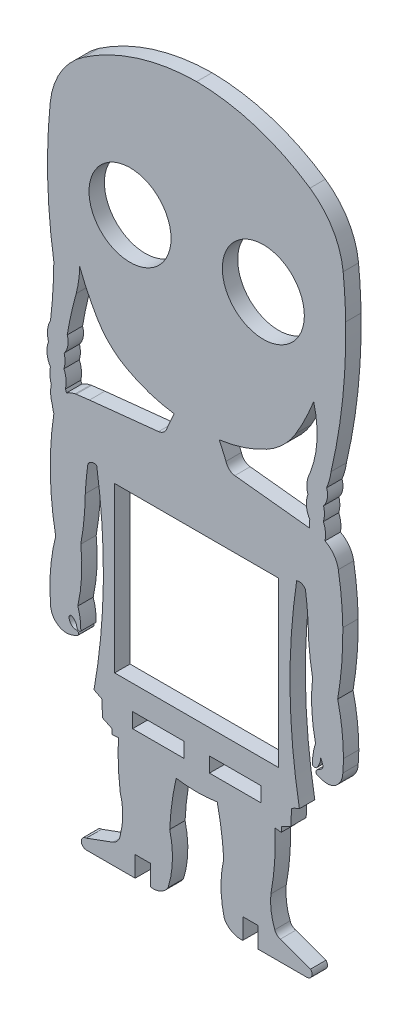
from build123d import *

# Parameters (mm, degrees)
MODEL_R                 = 8
MODEL_W                 = 10
MODEL_H                 = 2.9
MODEL_W_2               = 32
MODEL_H_2               = 32
SALIENTE_EXTRUIR1_DEPTH = 3


with BuildPart() as part:
    # Model → Saliente-Extruir1 (new body)
    with BuildSketch(Plane.XY):
        with BuildLine():
            Line((38.13338625, -11.98902119), (39.653006529, -12.774243223))
            Line((39.653006529, -12.774243223), (39.802898244, -15.912303294))
            Line((39.802898244, -15.912303294), (41.659424282, -16.81226138))
            Line((41.659424282, -16.81226138), (41.659570627, -17.81226137))
            Line((41.659570627, -17.81226137), (42.885100365, -17.686085819))
            ThreePointArc((42.885100365, -17.686085819), (42.872802779, -22.221519016), (43.240098472, -26.742072012))
            ThreePointArc((43.240098472, -26.742072012), (43.741813509, -30.284540527), (43.277058391, -33.832047235))
            ThreePointArc((43.277058391, -33.832047235), (42.843713702, -35.071902085), (41.821747011, -35.896894057))
            Line((41.821747011, -35.896894057), (36.619576914, -37.805682401))
            ThreePointArc((36.619576914, -37.805682401), (35.648987396, -38.830697612), (36.66279026, -39.812992857))
            Line((36.66279026, -39.812992857), (46.161532701, -39.811602768))
            Line((46.161532701, -39.811602768), (46.160947323, -35.811602811))
            Line((46.160947323, -35.811602811), (49.156750321, -35.811164391))
            Line((49.156750321, -35.811164391), (49.161532531, -39.810221609))
            ThreePointArc((49.161532531, -39.810221609), (51.099825083, -39.514249492), (52.57645016, -38.224227828))
            ThreePointArc((52.57645016, -38.224227828), (53.427829994, -33.234025723), (52.896261461, -28.199703568))
            ThreePointArc((52.896261461, -28.199703568), (53.321482121, -23.531856748), (54.153881511, -18.919187477))
            ThreePointArc((54.153881511, -18.919187477), (58.157636, -19.235830008), (62.161344106, -18.918601553))
            ThreePointArc((62.161344106, -18.918601553), (62.974942691, -23.410097559), (63.434714055, -27.951472827))
            ThreePointArc((63.434714055, -27.951472827), (62.903519075, -32.937753167), (63.54579815, -37.910945033))
            ThreePointArc((63.54579815, -37.910945033), (65.056116274, -39.421668423), (67.156750321, -39.809846983))
            Line((67.156750321, -39.809846983), (67.156750321, -35.809846983))
            Line((67.156750321, -35.809846983), (70.156750321, -35.809846983))
            Line((70.156750321, -35.809846983), (70.156750321, -39.809846983))
            Line((70.156750321, -39.809846983), (79.693755496, -39.809445684))
            ThreePointArc((79.693755496, -39.809445684), (80.593657018, -39.149406826), (80.377002549, -38.054630646))
            Line((80.377002549, -38.054630646), (74.477680062, -35.933884761))
            ThreePointArc((74.477680062, -35.933884761), (73.797838269, -35.555941667), (73.390760584, -34.8931343))
            ThreePointArc((73.390760584, -34.8931343), (72.679975093, -32.105941725), (72.627396562, -29.23002553))
            ThreePointArc((72.627396562, -29.23002553), (73.363432338, -23.480206676), (73.429944674, -17.683850784))
            Line((73.429944674, -17.683850784), (74.655492864, -17.809846983))
            Line((74.655492864, -17.809846983), (74.655492864, -16.809846983))
            Line((74.655492864, -16.809846983), (76.511887179, -15.909617214))
            Line((76.511887179, -15.909617214), (76.661319654, -12.771535241))
            ThreePointArc((76.661319654, -12.771535241), (77.407588898, -12.361254496), (78.198982306, -12.046699973))
            ThreePointArc((78.198982306, -12.046699973), (76.369057771, 7.049663622), (77.658007778, 26.190153017))
            ThreePointArc((77.658007778, 26.190153017), (78.625759658, 26.202004714), (79.370870097, 25.584352225))
            ThreePointArc((79.370870097, 25.584352225), (79.683559437, 22.93101885), (79.884170291, 20.26686647))
            ThreePointArc((79.884170291, 20.26686647), (80.128803281, 15.76516974), (80.75659962, 11.300755949))
            ThreePointArc((80.75659962, 11.300755949), (80.608595679, 5.911597181), (81.336651671, 0.569793003))
            ThreePointArc((81.336651671, 0.569793003), (80.874239414, -1.377695927), (80.75123227, -3.375546641))
            ThreePointArc((80.75123227, -3.375546641), (81.132788068, -3.557162673), (81.54344173, -3.457499344))
            ThreePointArc((81.54344173, -3.457499344), (82.123620398, -2.472655714), (82.365920426, -1.355599334))
            Line((82.365920426, -1.355599334), (82.731532261, -2.337573054))
            ThreePointArc((82.731532261, -2.337573054), (82.716273485, -2.891757606), (82.348186231, -3.306323791))
            ThreePointArc((82.348186231, -3.306323791), (81.9194858, -3.566874198), (81.519346366, -3.869461388))
            ThreePointArc((81.519346366, -3.869461388), (81.394346017, -4.250479501), (81.594913038, -4.597715386))
            ThreePointArc((81.594913038, -4.597715386), (82.546157979, -4.951267012), (83.546305166, -5.123230082))
            ThreePointArc((83.546305166, -5.123230082), (84.803821734, -4.845241985), (85.812572918, -4.044588284))
            ThreePointArc((85.812572918, -4.044588284), (86.435586593, -3.002992591), (86.658007778, -1.809846983))
            ThreePointArc((86.658007778, -1.809846983), (86.739204411, -0.560861795), (86.777674837, 0.690168549))
            ThreePointArc((86.777674837, 0.690168549), (86.496792688, 5.47303796), (85.658007778, 10.190153017))
            ThreePointArc((85.658007778, 10.190153017), (86.445024112, 16.448601458), (86.659989285, 22.752676456))
            ThreePointArc((86.659989285, 22.752676456), (86.395853577, 27.453838391), (85.786017751, 32.122755982))
            ThreePointArc((85.786017751, 32.122755982), (84.900900015, 34.200326378), (83.191960731, 35.67655762))
            ThreePointArc((83.191960731, 35.67655762), (83.267506137, 37.256812295), (82.874566252, 38.789297269))
            ThreePointArc((82.874566252, 38.789297269), (83.076029916, 40.128033113), (82.908147107, 41.471393314))
            ThreePointArc((82.908147107, 41.471393314), (83.636168036, 43.069749641), (83.50522588, 44.821209481))
            ThreePointArc((83.50522588, 44.821209481), (84.042102073, 46.362379689), (84.364424293, 47.962239071))
            ThreePointArc((84.364424293, 47.962239071), (86.618595537, 61.237849866), (87.224806715, 74.68982511))
            ThreePointArc((87.224806715, 74.68982511), (87.056800285, 78.802763925), (86.728271279, 82.906001738))
            ThreePointArc((86.728271279, 82.906001738), (84.700461487, 89.074609987), (80.255619321, 93.808225772))
            ThreePointArc((80.255619321, 93.808225772), (69.72067189, 98.917356509), (58.156750321, 100.751491783))
            ThreePointArc((58.156750321, 100.751491783), (46.592828752, 98.917356509), (36.057881322, 93.808225772))
            ThreePointArc((36.057881322, 93.808225772), (31.613039156, 89.074609987), (29.585229363, 82.906001738))
            ThreePointArc((29.585229363, 82.906001738), (29.102545512, 69.627136778), (30.294955036, 56.393112527))
            ThreePointArc((30.294955036, 56.393112527), (30.113174416, 51.282986839), (29.655492864, 46.190153017))
            ThreePointArc((29.655492864, 46.190153017), (29.082963004, 44.310971202), (29.250253195, 42.353644268))
            ThreePointArc((29.250253195, 42.353644268), (28.963838604, 40.285926549), (29.618806019, 38.303880241))
            ThreePointArc((29.618806019, 38.303880241), (29.530635351, 36.823427951), (29.802364542, 35.365458028))
            ThreePointArc((29.802364542, 35.365458028), (29.675044266, 33.719440486), (30.000786224, 32.100960836))
            ThreePointArc((30.000786224, 32.100960836), (30.110421583, 31.410758304), (30.299083762, 30.73784967))
            ThreePointArc((30.299083762, 30.73784967), (29.605599069, 20.448881499), (30.655492864, 10.190153017))
            ThreePointArc((30.655492864, 10.190153017), (29.658917683, 4.231534282), (29.655492864, -1.809846983))
            ThreePointArc((29.655492864, -1.809846983), (29.877914049, -3.002992591), (30.500927724, -4.044588284))
            ThreePointArc((30.500927724, -4.044588284), (31.814902322, -4.920630356), (33.391717798, -5.007991174))
            ThreePointArc((33.391717798, -5.007991174), (34.137122565, -4.790515502), (34.843036496, -4.467081651))
            ThreePointArc((34.843036496, -4.467081651), (35.127127166, -3.999561224), (34.739159104, -3.613862324))
            ThreePointArc((34.739159104, -3.613862324), (33.67716173, -3.184791782), (33.283131978, -2.10930096))
            ThreePointArc((33.283131978, -2.10930096), (33.494826851, -1.718657356), (33.938344185, -1.745294179))
            ThreePointArc((33.938344185, -1.745294179), (34.493195611, -2.316132502), (34.787693342, -3.055718592))
            ThreePointArc((34.787693342, -3.055718592), (34.985784548, -3.414741828), (35.387363334, -3.497641092))
            ThreePointArc((35.387363334, -3.497641092), (35.476115329, -3.445875915), (35.555217619, -3.380306275))
            ThreePointArc((35.555217619, -3.380306275), (35.439451794, -1.379324135), (34.975517408, 0.570572308))
            ThreePointArc((34.975517408, 0.570572308), (35.70649142, 5.91220389), (35.555930222, 11.301515747))
            ThreePointArc((35.555930222, 11.301515747), (36.184195727, 15.765528896), (36.429330352, 20.26686647))
            ThreePointArc((36.429330352, 20.26686647), (36.629941206, 22.93101885), (36.942630546, 25.584352225))
            ThreePointArc((36.942630546, 25.584352225), (37.687740984, 26.202004714), (38.655492864, 26.190153017))
            ThreePointArc((38.655492864, 26.190153017), (39.951524478, 7.079272516), (38.13338625, -11.98902119))
        make_face()
        with Locations((45.156750321, 71.712196279)):
            Circle(MODEL_R, mode=Mode.SUBTRACT)
        with Locations((71.156750321, 71.712196279)):
            Circle(MODEL_R, mode=Mode.SUBTRACT)
        with BuildLine():
            Line((62.563797699, 42.448688608), (63.883863041, 39.480536552))
            ThreePointArc((63.883863041, 39.480536552), (64.489395861, 38.422507509), (65.596662509, 37.912550624))
            Line((65.596662509, 37.912550624), (80.129802187, 36.337902427))
            ThreePointArc((80.129802187, 36.337902427), (80.131262399, 37.066798655), (80.219659568, 37.7903163))
            ThreePointArc((80.219659568, 37.7903163), (79.564692153, 39.772362608), (79.851106744, 41.840080327))
            ThreePointArc((79.851106744, 41.840080327), (79.683816553, 43.797407261), (80.256346413, 45.676589076))
            ThreePointArc((80.256346413, 45.676589076), (81.623379165, 51.836282911), (80.978461998, 58.112801734))
            ThreePointArc((80.978461998, 58.112801734), (79.388294211, 54.465766157), (77.499872133, 50.963857515))
            ThreePointArc((77.499872133, 50.963857515), (75.026874588, 47.839044876), (71.818346679, 45.475674498))
            ThreePointArc((71.818346679, 45.475674498), (67.331870743, 43.531711387), (62.563797699, 42.448688608))
        make_face(mode=Mode.SUBTRACT)
        with BuildLine():
            Line((34.438521627, 36.148814617), (34.657873731, 36.19094302))
            Line((34.657873731, 36.19094302), (37.252216007, 36.508696647))
            Line((37.252216007, 36.508696647), (50.716761984, 37.912867984))
            ThreePointArc((50.716761984, 37.912867984), (51.824045775, 38.422787644), (52.429614164, 39.480796329))
            Line((52.429614164, 39.480796329), (53.749684561, 42.448691023))
            ThreePointArc((53.749684561, 42.448691023), (48.981621088, 43.531714269), (44.495153964, 45.475674498))
            ThreePointArc((44.495153964, 45.475674498), (41.286626055, 47.839044876), (38.813628509, 50.963857515))
            ThreePointArc((38.813628509, 50.963857515), (36.932116389, 54.451571283), (35.346450678, 58.083361398))
            ThreePointArc((35.346450678, 58.083361398), (35.140573785, 55.617044353), (34.655492864, 53.190153017))
            ThreePointArc((34.655492864, 53.190153017), (33.676679454, 49.285480401), (32.904372331, 45.334773422))
            ThreePointArc((32.904372331, 45.334773422), (33.035314487, 43.583313582), (32.307293558, 41.984957255))
            ThreePointArc((32.307293558, 41.984957255), (32.475176367, 40.641597054), (32.273712703, 39.30286121))
            ThreePointArc((32.273712703, 39.30286121), (32.675480163, 37.675357651), (32.550370024, 36.003672161))
            ThreePointArc((32.550370024, 36.003672161), (32.663729101, 35.738818535), (32.763134119, 35.468418154))
            ThreePointArc((32.763134119, 35.468418154), (33.569813617, 35.884984943), (34.438521627, 36.148814617))
        make_face(mode=Mode.SUBTRACT)
        with Locations((65.656750321, -13.359846983)):
            Rectangle(MODEL_W, MODEL_H, mode=Mode.SUBTRACT)
        with Locations((50.656750321, -13.359846983)):
            Rectangle(MODEL_W, MODEL_H, mode=Mode.SUBTRACT)
        with Locations((58.156750321, 8.868187034)):
            Rectangle(MODEL_W_2, MODEL_H_2, mode=Mode.SUBTRACT)
    extrude(amount=SALIENTE_EXTRUIR1_DEPTH)


solid = part.part
